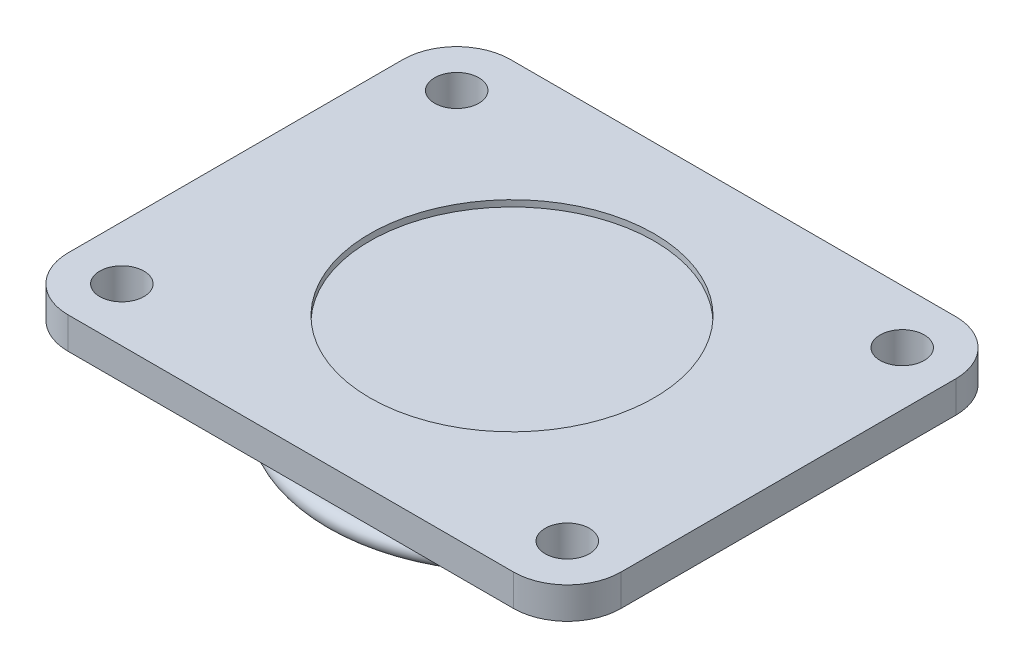
from build123d import *

# Parameters (mm, degrees)
SKETCH1_R           = 7
BOSS_EXTRUDE2_DEPTH = 10
SKETCH3_R           = 56
BOSS_EXTRUDE4_DEPTH = 20
SKETCH5_R           = 3
SKETCH6_R           = 7.5
BOSS_EXTRUDE5_DEPTH = 25
CHAMFER1_SIZE       = 1
SKETCH7_R           = 45
CUT_EXTRUDE2_DEPTH  = 2


with BuildPart() as part:
    # Sketch1 → Boss-Extrude2 (new body)
    with BuildSketch(Plane(origin=(0, 0, 0), x_dir=(1, 0, 0), z_dir=(0, 1, 0))):
        with BuildLine():
            Line((-70.5, 70), (70.5, 70))
            ThreePointArc((70.5, 70), (82.52081528, 65.02081528), (87.5, 53))
            Line((87.5, 53), (87.5, -53))
            ThreePointArc((87.5, -53), (82.52081528, -65.02081528), (70.5, -70))
            Line((70.5, -70), (-70.5, -70))
            ThreePointArc((-70.5, -70), (-82.52081528, -65.02081528), (-87.5, -53))
            Line((-87.5, -53), (-87.5, 53))
            ThreePointArc((-87.5, 53), (-82.52081528, 65.02081528), (-70.5, 70))
        make_face()
        with Locations((-70.5, 53)):
            Circle(SKETCH1_R, mode=Mode.SUBTRACT)
        with Locations((70.5, 53)):
            Circle(SKETCH1_R, mode=Mode.SUBTRACT)
        with Locations((70.5, -53)):
            Circle(SKETCH1_R, mode=Mode.SUBTRACT)
        with Locations((-70.5, -53)):
            Circle(SKETCH1_R, mode=Mode.SUBTRACT)
    extrude(amount=BOSS_EXTRUDE2_DEPTH)

    # Sketch3 → Boss-Extrude4 (add)
    with BuildSketch(Plane(origin=(0, 0, 0), x_dir=(-1, 0, 0), z_dir=(0, -1, 0))):
        Circle(SKETCH3_R)
    extrude(amount=BOSS_EXTRUDE4_DEPTH)

    # Sketch5 → Revolve1 (revolve)
    with BuildSketch(Plane(origin=(0, 0, 0), x_dir=(0, 0, -1), z_dir=(1, 0, 0))):
        with Locations((-56, -17)):
            Circle(SKETCH5_R)
    revolve(axis=Axis((0, 0, 0), (0, -1, 0)))

    # Sketch6 → Boss-Extrude5 (add)
    with BuildSketch(Plane.XZ.offset(20)):
        Circle(SKETCH6_R)
    extrude(amount=BOSS_EXTRUDE5_DEPTH)

    # Chamfer1
    chamfer1_edges = [part.edges().sort_by_distance(p)[0] for p in [
        (-7.5, -45, 0),
    ]]
    chamfer(chamfer1_edges, length=CHAMFER1_SIZE)

    # Sketch7 → Cut-Extrude2 (cut)
    with BuildSketch(Plane(origin=(0, 10, 0), x_dir=(1, 0, 0), z_dir=(0, 1, 0))):
        Circle(SKETCH7_R)
    extrude(amount=-CUT_EXTRUDE2_DEPTH, mode=Mode.SUBTRACT)


solid = part.part
